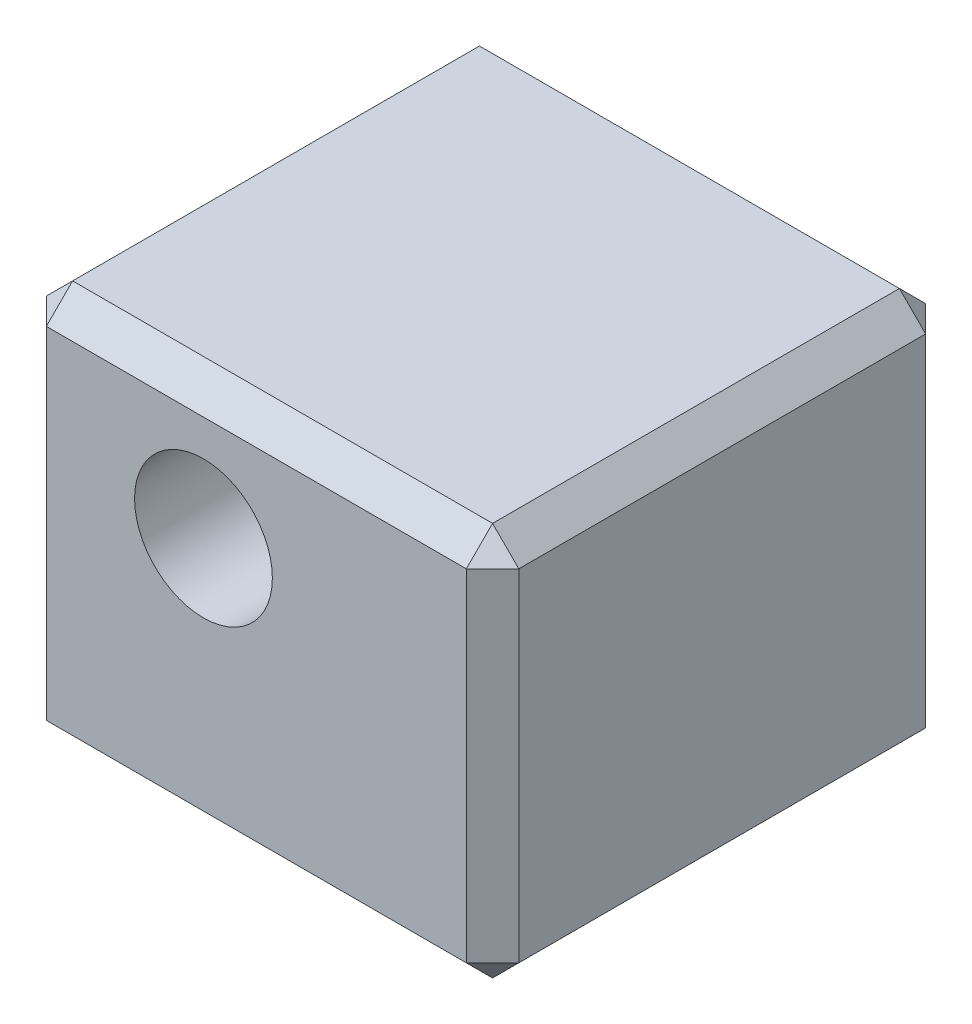
from build123d import *

# Parameters (mm, degrees)
SKETCH1_W           = 18
SKETCH1_H           = 18
BOSS_EXTRUDE1_DEPTH = 15
SKETCH2_R           = 2.625
CUT_EXTRUDE1_DEPTH  = 19
SKETCH3_R           = 5.75
CUT_EXTRUDE2_DEPTH  = 7
SKETCH5_W           = 18
SKETCH5_H           = 15
CUT_EXTRUDE3_DEPTH  = 0.5
CHAMFER1_SIZE       = 1


with BuildPart() as part:
    # Sketch1 → Boss-Extrude1 (new body)
    with BuildSketch(Plane(origin=(0, 0, 0), x_dir=(1, 0, 0), z_dir=(0, 1, 0))):
        with Locations((-4.272296667, 11.628336988)):
            Rectangle(SKETCH1_W, SKETCH1_H)
    extrude(amount=BOSS_EXTRUDE1_DEPTH)

    # Sketch2 → Cut-Extrude1 (cut, through all)
    with BuildSketch(Plane.XY.offset(-2.628336988)):
        with Locations((-6.286796667, 10)):
            Circle(SKETCH2_R)
    extrude(amount=-CUT_EXTRUDE1_DEPTH, mode=Mode.SUBTRACT)

    # Sketch3 → Cut-Extrude2 (cut)
    with BuildSketch(Plane.XZ):
        with Locations((-4.272296667, -11.628336988)):
            Circle(SKETCH3_R)
    extrude(amount=-CUT_EXTRUDE2_DEPTH, mode=Mode.SUBTRACT)

    # Sketch5 → Cut-Extrude3 (cut)
    with BuildSketch(Plane.XY.offset(-2.628336988)):
        with Locations((-4.272296667, 7.5)):
            Rectangle(SKETCH5_W, SKETCH5_H)
    extrude(amount=-CUT_EXTRUDE3_DEPTH, mode=Mode.SUBTRACT)

    # Chamfer1
    chamfer1_edges = [part.edges().sort_by_distance(p)[0] for p in [
        (-4.272296667, 15, -20.628336988),
        (4.727703333, 0, -11.878336988),
        (4.727703333, 15, -11.878336988),
        (-4.272296667, 15, -3.128336988),
        (4.727703333, 7.5, -3.128336988),
        (-4.272296667, 0, -3.128336988),
        (-13.272296667, 7.5, -3.128336988),
        (-13.272296667, 15, -11.878336988),
        (-4.272296667, 0, -20.628336988),
        (-13.272296667, 0, -11.878336988),
        (-13.272296667, 7.5, -20.628336988),
        (4.727703333, 7.5, -20.628336988),
    ]]
    chamfer(chamfer1_edges, length=CHAMFER1_SIZE)


solid = part.part
